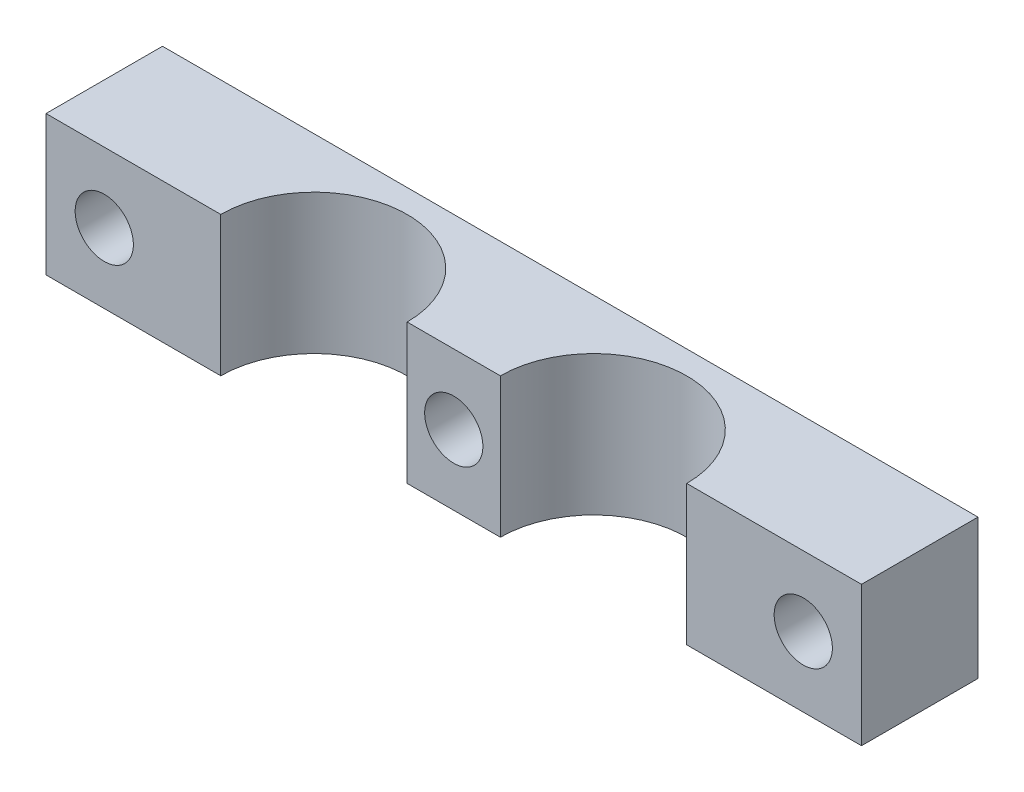
from build123d import *

# Parameters (mm, degrees)
BOSS_EXTRUDE1_DEPTH = 12
SKETCH2_R           = 2.5
CUT_EXTRUDE1_DEPTH  = 10


with BuildPart() as part:
    # Sketch1 → Boss-Extrude1 (new body)
    with BuildSketch(Plane(origin=(0, 0, 0), x_dir=(1, 0, 0), z_dir=(0, 1, 0))):
        with BuildLine():
            Line((35, 5), (-35, 5))
            Line((-35, 5), (-35, -5))
            Line((-35, -5), (-20, -5))
            ThreePointArc((-20, -5), (-12, 3), (-4, -5))
            Line((-4, -5), (4, -5))
            ThreePointArc((4, -5), (12, 3), (20, -5))
            Line((20, -5), (35, -5))
            Line((35, -5), (35, 5))
        make_face()
    extrude(amount=BOSS_EXTRUDE1_DEPTH)

    # Sketch2 → Cut-Extrude1 (cut)
    with BuildSketch(Plane(origin=(0, 0, -5), x_dir=(-1, 0, 0), z_dir=(0, 0, -1))):
        with Locations((0, 6)):
            Circle(SKETCH2_R)
        with Locations((-30, 6)):
            Circle(SKETCH2_R)
        with Locations((30, 6)):
            Circle(SKETCH2_R)
    extrude(amount=-CUT_EXTRUDE1_DEPTH, mode=Mode.SUBTRACT)


solid = part.part
